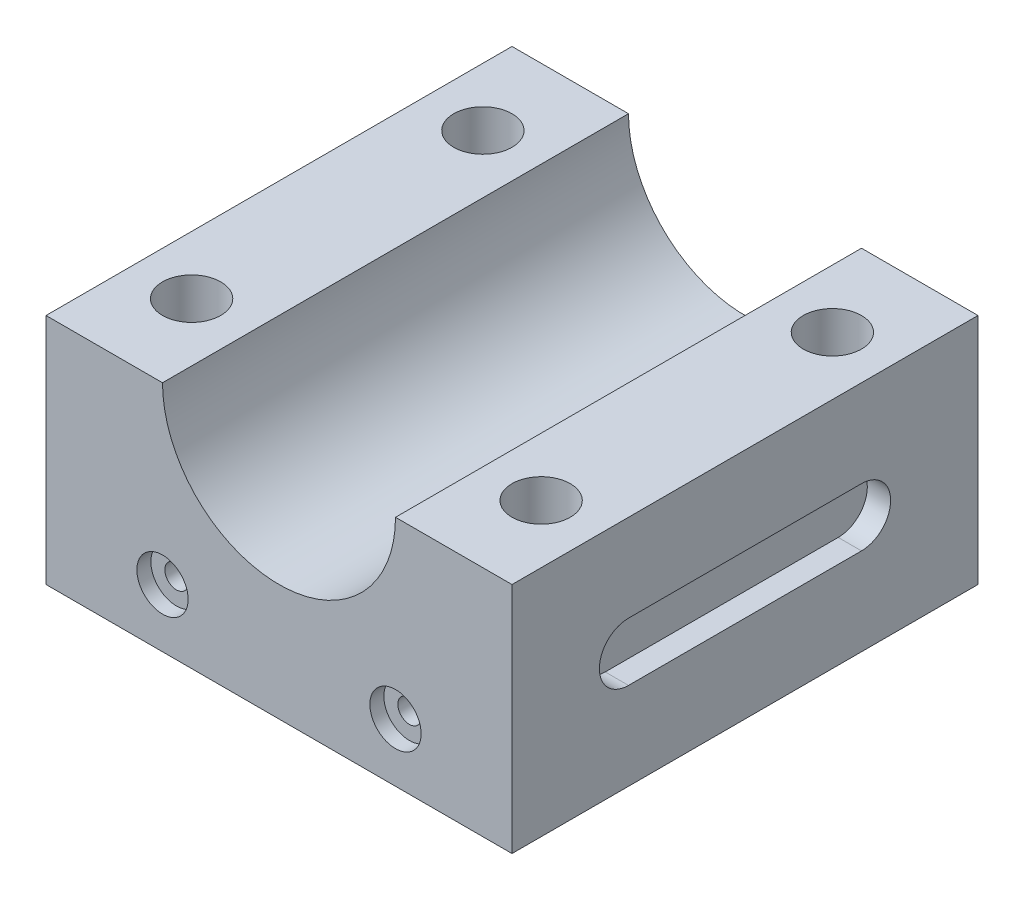
from build123d import *

# Parameters (mm, degrees)
BOSS_EXTRUDE1_DEPTH                                 = 50.8
SKETCH2_R                                           = 6.35
CUT_EXTRUDE1_DEPTH                                  = 51.8
LPATTERN1_COUNT                                     = 2
LPATTERN1_PITCH                                     = 76.2
LPATTERN1_COUNT_DIR2                                = 2
LPATTERN1_PITCH_DIR2                                = 63.5
CBORE_FOR_00_BINDING_HEAD_MACHINE_SCREW_D           = 5.08
CBORE_FOR_00_BINDING_HEAD_MACHINE_SCREW_CBORE_D     = 11.176
CBORE_FOR_00_BINDING_HEAD_MACHINE_SCREW_CBORE_DEPTH = 3.048
CUT_EXTRUDE6_DEPTH                                  = 5.08


with BuildPart() as part:
    # Sketch1 → Boss-Extrude1 (new body, symmetric)
    with BuildSketch(Plane.XY):
        with BuildLine():
            Line((25.4, 25.4), (50.8, 25.4))
            Line((50.8, 25.4), (50.8, -25.4))
            Line((50.8, -25.4), (-50.8, -25.4))
            Line((-50.8, -25.4), (-50.8, 25.4))
            Line((-50.8, 25.4), (-25.4, 25.4))
            ThreePointArc((-25.4, 25.4), (0, 0), (25.4, 25.4))
        make_face()
    extrude(amount=BOSS_EXTRUDE1_DEPTH, both=True)

    # Sketch2 → Cut-Extrude1 (cut, through all)
    with BuildSketch(Plane(origin=(0, 25.4, 0), x_dir=(1, 0, 0), z_dir=(0, 1, 0))):
        with Locations((-38.1, 31.75)):
            Circle(SKETCH2_R)
    cut_extrude1 = extrude(amount=-CUT_EXTRUDE1_DEPTH, mode=Mode.SUBTRACT)

    # LPattern1: Cut-Extrude1 2 × 2
    with Locations(*[(i * LPATTERN1_PITCH, 0, j * LPATTERN1_PITCH_DIR2) for i in range(LPATTERN1_COUNT) for j in range(LPATTERN1_COUNT_DIR2) if (i, j) != (0, 0)]):
        add(cut_extrude1, mode=Mode.SUBTRACT)

    # CBORE for #00 Binding Head Machine Screw1 (through all)
    with Locations(Plane.XY.offset(50.8)):
        with Locations((-25.4, -12.7), (25.4, -12.7)):
            CounterBoreHole(CBORE_FOR_00_BINDING_HEAD_MACHINE_SCREW_D / 2, CBORE_FOR_00_BINDING_HEAD_MACHINE_SCREW_CBORE_D / 2, CBORE_FOR_00_BINDING_HEAD_MACHINE_SCREW_CBORE_DEPTH)

    # Sketch7 → Cut-Extrude6 (cut)
    with BuildSketch(Plane(origin=(50.8, 0, 0), x_dir=(0, 0, -1), z_dir=(1, 0, 0))):
        with BuildLine():
            Line((-25.4, 6.35), (25.4, 6.35))
            ThreePointArc((25.4, 6.35), (31.75, 0), (25.4, -6.35))
            Line((25.4, -6.35), (-25.4, -6.35))
            ThreePointArc((-25.4, -6.35), (-31.75, 0), (-25.4, 6.35))
        make_face()
    extrude(amount=-CUT_EXTRUDE6_DEPTH, mode=Mode.SUBTRACT)


solid = part.part
